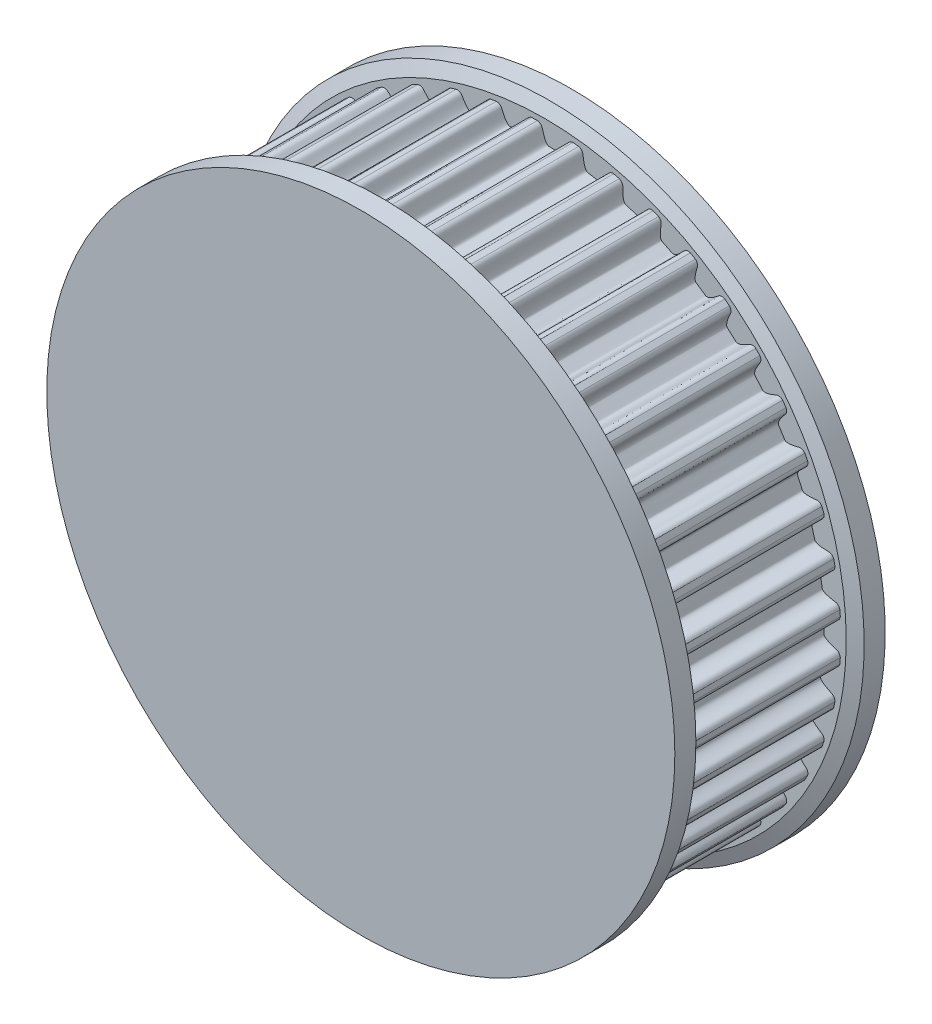
from build123d import *

# Parameters (mm, degrees)
TOOTHEXTRUDECUTGEARBELT01_DEPTH = 3.749999944
PATTERNGEARBELT01_COUNT         = 45
BOREREVOLVESKETCH_W             = 10.547999842
BOREREVOLVESKETCH_H             = 5
SKETCH1_W                       = 97.771962469
SKETCH1_H                       = 17.615630765
CUT_EXTRUDE1_DEPTH              = 16.085944652
CUT_EXTRUDE1_DEPTH_BACK         = 16.085944652
SKETCH2_R                       = 14.92749819
BOSS_EXTRUDE1_DEPTH             = 1
SKETCH3_R                       = 7.17914148
BOSS_EXTRUDE2_DEPTH             = 8
SKETCH4_R                       = 14.92749819
BOSS_EXTRUDE3_DEPTH             = 1


with BuildPart() as part:
    # SketchRevolveGearBelt01 → GearBelt01 (revolve)
    with BuildSketch(Plane(origin=(0, 0, 0), x_dir=(0, 0, -1), z_dir=(1, 0, 0))):
        Polygon((5.273999921, 0), (5.273999921, 12.823944686), (4.511999932, 12.823944686), (4.511999932, 14.172373441), (4.769626867, 14.794339881), (4.065630673, 15.085944652), (3.749999944, 14.323944663), (3.749999944, 14.067828847), (-3.749999944, 14.067828847), (-3.749999944, 14.323944663), (-4.065630673, 15.085944652), (-4.769626867, 14.794339881), (-4.511999932, 14.172373441), (-4.511999932, 12.823944686), (-5.273999921, 12.823944686), (-5.273999921, 0), align=None)
    revolve(axis=Axis((0, 0, 0), (0, 0, -1)))

    # SketchToothGearBelt01 → ToothExtrudeCutGearBelt01 (cut, symmetric)
    with BuildSketch(Plane.XY):
        with BuildLine():
            ThreePointArc((14.043084471, 0.861354263), (14.069475918, 0), (14.043084471, -0.861354263))
            add(Edge.make_bspline(
                [(14.043084471, -0.861354263), (14.043058781, -0.844101864), (14.040492342, -0.818228868), (14.032137768, -0.784709364), (14.023465803, -0.760295074), (14.012469046, -0.736835911), (13.999251089, -0.714552553), (13.983936215, -0.693654915), (13.966668813, -0.674338797), (13.947610353, -0.656789108), (13.926943964, -0.641159251), (13.904849963, -0.627640116), (13.881589074, -0.616195395), (13.841455192, -0.601967276), (13.790375804, -0.586536337), (13.730125143, -0.56748088), (13.677675764, -0.549825744), (13.628396181, -0.532186885), (13.582292013, -0.514546571), (13.539360798, -0.496909288), (13.49960175, -0.479273964), (13.463013271, -0.461640694), (13.429593451, -0.444008949), (13.399339796, -0.426377751), (13.37224928, -0.408745201), (13.348318075, -0.391107907), (13.327542882, -0.373460068), (13.309918809, -0.355792311), (13.295452316, -0.33809054), (13.28413155, -0.320336691), (13.276045677, -0.302512788), (13.271004914, -0.28461649), (13.26880367, -0.250312541), (13.271985936, -0.199994192), (13.272129991, -0.1333067), (13.272898524, -0.066656855), (13.273012596, 0), (13.272898524, 0.066656855), (13.272129991, 0.1333067), (13.271985936, 0.199994192), (13.26880367, 0.250312541), (13.271004914, 0.28461649), (13.276045677, 0.302512788), (13.28413155, 0.320336691), (13.295452316, 0.33809054), (13.309918809, 0.355792311), (13.327542882, 0.373460068), (13.348318075, 0.391107907), (13.37224928, 0.408745201), (13.399339796, 0.426377751), (13.429593451, 0.444008949), (13.463013271, 0.461640694), (13.49960175, 0.479273964), (13.539360798, 0.496909288), (13.582292013, 0.514546571), (13.628396181, 0.532186885), (13.677675764, 0.549825744), (13.730125143, 0.56748088), (13.790375804, 0.586536337), (13.841455192, 0.601967276), (13.881589074, 0.616195395), (13.904849963, 0.627640116), (13.926943964, 0.641159251), (13.947610353, 0.656789108), (13.966668813, 0.674338797), (13.983936215, 0.693654915), (13.999251089, 0.714552553), (14.012469046, 0.736835911), (14.023465803, 0.760295074), (14.032137768, 0.784709364), (14.040492342, 0.818228868), (14.043058781, 0.844101864), (14.043084471, 0.861354263)],
                knots=[0, 0, 0, 0, 0.019740435, 0.029610652, 0.03948087, 0.049351087, 0.059221305, 0.069091522, 0.078961739, 0.088831957, 0.098702174, 0.108572392, 0.118442609, 0.128312826, 0.157264894, 0.179529844, 0.200642324, 0.220609456, 0.239439658, 0.257142972, 0.273731486, 0.289219898, 0.303626276, 0.316973079, 0.329288567, 0.340608726, 0.350979907, 0.36046239, 0.369135001, 0.37710065, 0.384491834, 0.391473832, 0.398241965, 0.423700314, 0.449133543, 0.474566771, 0.5, 0.525433229, 0.550866457, 0.576299686, 0.601758035, 0.608526168, 0.615508166, 0.62289935, 0.630864999, 0.63953761, 0.649020093, 0.659391274, 0.670711433, 0.683026921, 0.696373724, 0.710780102, 0.726268514, 0.742857028, 0.760560342, 0.779390544, 0.799357676, 0.820470156, 0.842735106, 0.871687174, 0.881557391, 0.891427608, 0.901297826, 0.911168043, 0.921038261, 0.930908478, 0.940778695, 0.950648913, 0.96051913, 0.970389348, 0.980259565, 1, 1, 1, 1], degree=3))
        make_face()
    toothextrudecutgearbelt01 = extrude(amount=TOOTHEXTRUDECUTGEARBELT01_DEPTH, both=True, mode=Mode.SUBTRACT)

    # PatternGearBelt01: ToothExtrudeCutGearBelt01 ×45 about axis
    patterngearbelt01_axis = Axis((0, 0, 55), (0, 0, -1))
    for i in range(1, PATTERNGEARBELT01_COUNT):
        add(toothextrudecutgearbelt01.rotate(patterngearbelt01_axis, i * 360 / PATTERNGEARBELT01_COUNT), mode=Mode.SUBTRACT)

    # BoreRevolveSketch → BoreRevolveCut (revolve, cut)
    with BuildSketch(Plane(origin=(0, 0, 0), x_dir=(0, 0, -1), z_dir=(1, 0, 0))):
        with Locations((0, 2.5)):
            Rectangle(BOREREVOLVESKETCH_W, BOREREVOLVESKETCH_H)
    revolve(axis=Axis((0, 0, 0), (0, 0, -1)), mode=Mode.SUBTRACT)

    # Sketch1 → Cut-Extrude1 (cut, two sides)
    with BuildSketch(Plane(origin=(0, 0, 0), x_dir=(1, 0, 0), z_dir=(0, 1, 0))) as cut_extrude1_sk:
        with Locations((-9.941056832, 12.807815383)):
            Rectangle(SKETCH1_W, SKETCH1_H)
        with Locations((-9.941056832, -12.807815383)):
            Rectangle(SKETCH1_W, SKETCH1_H)
    extrude(amount=CUT_EXTRUDE1_DEPTH, mode=Mode.SUBTRACT)
    extrude(cut_extrude1_sk.sketch, amount=-CUT_EXTRUDE1_DEPTH_BACK, mode=Mode.SUBTRACT)

    # Sketch2 → Boss-Extrude1 (add)
    with BuildSketch(Plane.XY.offset(4)):
        Circle(SKETCH2_R)
    extrude(amount=BOSS_EXTRUDE1_DEPTH)

    # Sketch3 → Boss-Extrude2 (add)
    with BuildSketch(Plane(origin=(0, 0, -4), x_dir=(-1, 0, 0), z_dir=(0, 0, -1))):
        Circle(SKETCH3_R)
    extrude(amount=-BOSS_EXTRUDE2_DEPTH)

    # Sketch4 → Boss-Extrude3 (add)
    with BuildSketch(Plane(origin=(0, 0, -4), x_dir=(-1, 0, 0), z_dir=(0, 0, -1))):
        Circle(SKETCH4_R)
    extrude(amount=BOSS_EXTRUDE3_DEPTH)


solid = part.part
